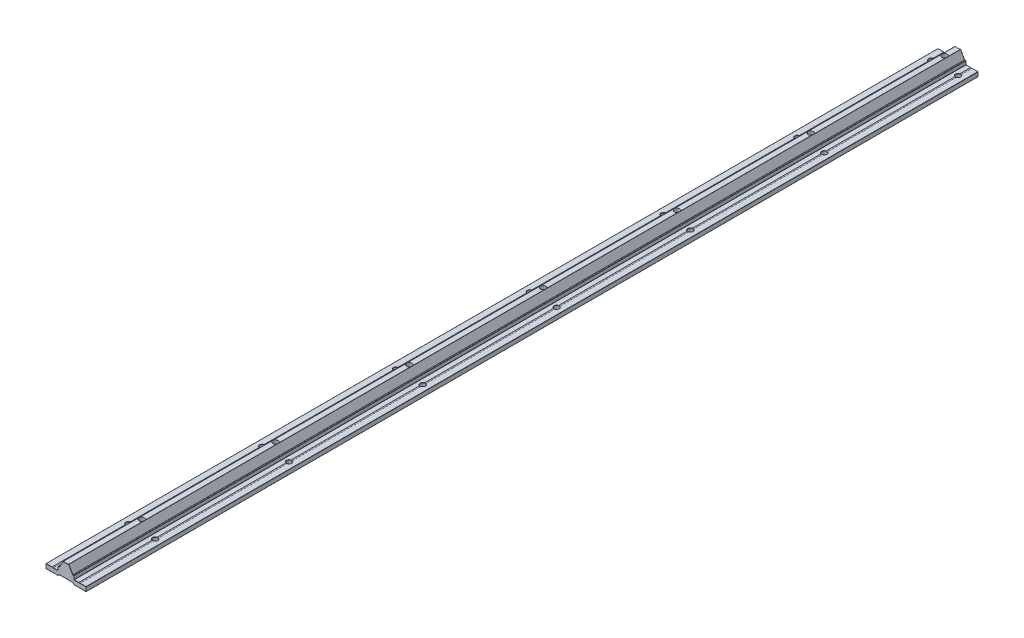
from build123d import *

# Parameters (mm, degrees)
BOSS_EXTRUDE1_DEPTH        = 1000
FILLET1_R                  = 0.2
SKETCH2_R                  = 2.75
CUT_EXTRUDE1_DEPTH         = 5
CHAMFER1_SIZE              = 0.2
LPATTERN1_COUNT            = 7
LPATTERN1_PITCH            = 150
CHAMFER1_OF_LPATTERN1_SIZE = 0.2
SKETCH3_R                  = 3
CUT_EXTRUDE2_DEPTH         = 16.462216412
SKETCH4_R                  = 5
CUT_EXTRUDE3_DEPTH         = 6
LPATTERN2_COUNT            = 7
LPATTERN2_PITCH            = 150
SKETCH5_R                  = 0.8
CUT_EXTRUDE6_DEPTH         = 1001.0000001


with BuildPart() as part:
    # Sketch1 → Boss-Extrude1 (new body)
    with BuildSketch(Plane.XY):
        with BuildLine():
            Line((-3, 0), (-7.618802154, -8))
            Line((-7.618802154, -8), (-9, -8))
            Line((-9, -8), (-9, -12))
            Line((-9, -12), (-22.5, -12))
            Line((-22.5, -12), (-22.5, -17))
            Line((-22.5, -17), (-9, -17))
            Line((-9, -17), (-7.618802154, -15.5))
            Line((-7.618802154, -15.5), (7.618802154, -15.5))
            Line((7.618802154, -15.5), (9, -17))
            Line((9, -17), (22.5, -17))
            Line((22.5, -17), (22.5, -12))
            Line((22.5, -12), (9, -12))
            Line((9, -12), (9, -8))
            Line((9, -8), (7.618802154, -8))
            Line((7.618802154, -8), (3, 0))
            ThreePointArc((3, 0), (0, -0.460607986), (-3, 0))
        make_face()
    extrude(amount=BOSS_EXTRUDE1_DEPTH)

    # Fillet1
    fillet1_edges = [part.edges().sort_by_distance(p)[0] for p in [
        (0, -15.5, 1000),
        (8.309401077, -16.25, 1000),
        (-22.5, -14.5, 0),
        (-15.75, -12, 0),
        (-9, -10, 0),
        (-8.309401077, -8, 0),
        (-5.309401077, -4, 0),
        (15.75, -17, 1000),
        (0, -0.460607986, 0),
        (5.309401077, -4, 0),
        (8.309401077, -8, 0),
        (9, -10, 0),
        (15.75, -12, 0),
        (22.5, -14.5, 0),
        (15.75, -17, 0),
        (8.309401077, -16.25, 0),
        (22.5, -14.5, 1000),
        (0, -15.5, 0),
        (-8.309401077, -16.25, 0),
        (-15.75, -17, 0),
        (15.75, -12, 1000),
        (9, -10, 1000),
        (-22.5, -17, 500),
        (-22.5, -12, 500),
        (-9, -12, 500),
        (-9, -8, 500),
        (-7.618802154, -8, 500),
        (-3, 0, 500),
        (3, 0, 500),
        (7.618802154, -8, 500),
        (9, -8, 500),
        (9, -12, 500),
        (22.5, -12, 500),
        (22.5, -17, 500),
        (9, -17, 500),
        (7.618802154, -15.5, 500),
        (-7.618802154, -15.5, 500),
        (-9, -17, 500),
        (8.309401077, -8, 1000),
        (5.309401077, -4, 1000),
        (0, -0.460607986, 1000),
        (-5.309401077, -4, 1000),
        (-15.75, -17, 1000),
        (-8.309401077, -8, 1000),
        (-9, -10, 1000),
        (-15.75, -12, 1000),
        (-22.5, -14.5, 1000),
        (-8.309401077, -16.25, 1000),
    ]]
    fillet(fillet1_edges, radius=FILLET1_R)

    # Sketch2 → Cut-Extrude1 (cut)
    with BuildSketch(Plane.XZ.offset(17)):
        with Locations((-15, 15)):
            Circle(SKETCH2_R)
        with Locations((15, 15)):
            Circle(SKETCH2_R)
    cut_extrude1 = extrude(amount=-CUT_EXTRUDE1_DEPTH, mode=Mode.SUBTRACT)

    # Chamfer1
    chamfer1_edges = [part.edges().sort_by_distance(p)[0] for p in [
        (-17.75, -17, 15),
        (-17.75, -12, 15),
        (12.25, -17, 15),
        (12.25, -12, 15),
    ]]
    chamfer(chamfer1_edges, length=CHAMFER1_SIZE)

    # LPattern1: Cut-Extrude1 ×7
    with Locations(*[(0, 0, i * LPATTERN1_PITCH) for i in range(1, LPATTERN1_COUNT)]):
        add(cut_extrude1, mode=Mode.SUBTRACT)

    # Chamfer1 of LPattern1
    chamfer1_of_lpattern1_edges = [part.edges().sort_by_distance(p)[0] for p in [
        (-17.75, -17, 165),
        (-17.75, -12, 165),
        (12.25, -17, 165),
        (12.25, -12, 165),
        (-17.75, -17, 315),
        (-17.75, -12, 315),
        (12.25, -17, 315),
        (12.25, -12, 315),
        (-17.75, -17, 465),
        (-17.75, -12, 465),
        (12.25, -17, 465),
        (12.25, -12, 465),
        (-17.75, -17, 615),
        (-17.75, -12, 615),
        (12.25, -17, 615),
        (12.25, -12, 615),
        (-17.75, -17, 765),
        (-17.75, -12, 765),
        (12.25, -17, 765),
        (12.25, -12, 765),
        (-17.75, -17, 915),
        (-17.75, -12, 915),
        (12.25, -17, 915),
        (12.25, -12, 915),
    ]]
    chamfer(chamfer1_of_lpattern1_edges, length=CHAMFER1_OF_LPATTERN1_SIZE)

    # Sketch3 → Cut-Extrude2 (cut, through all)
    with BuildSketch(Plane.XZ.offset(15.5)):
        with Locations((0, 15)):
            Circle(SKETCH3_R)
    cut_extrude2 = extrude(amount=-CUT_EXTRUDE2_DEPTH, mode=Mode.SUBTRACT)

    # Sketch4 → Cut-Extrude3 (cut)
    with BuildSketch(Plane.XZ.offset(15.5)):
        with Locations((0, 15)):
            Circle(SKETCH4_R)
    cut_extrude3 = extrude(amount=-CUT_EXTRUDE3_DEPTH, mode=Mode.SUBTRACT)

    # LPattern2: Cut-Extrude2, Cut-Extrude3 ×7
    with Locations(*[(0, 0, i * LPATTERN2_PITCH) for i in range(1, LPATTERN2_COUNT)]):
        add(cut_extrude2, mode=Mode.SUBTRACT)
        add(cut_extrude3, mode=Mode.SUBTRACT)

    # Sketch5 → Cut-Extrude6 (cut, through all)
    with BuildSketch(Plane.XY):
        with Locations((-15, -11.6)):
            Circle(SKETCH5_R)
        with Locations((15, -11.6)):
            Circle(SKETCH5_R)
    extrude(amount=CUT_EXTRUDE6_DEPTH, mode=Mode.SUBTRACT)


solid = part.part
